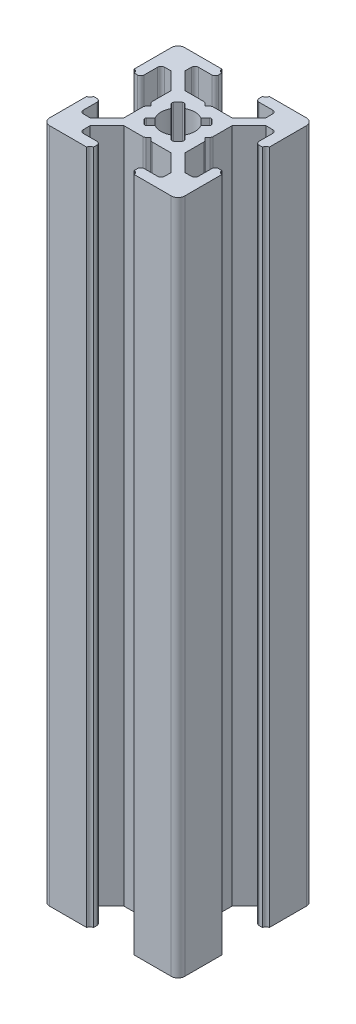
from build123d import *

# Parameters (mm, degrees)
BOSS_EXTRUDE1_DEPTH = 100
FILLET1_R           = 1
CUT_EXTRUDE1_DEPTH  = 101
FILLET2_R           = 0.5
FILLET3_R           = 0.25


with BuildPart() as part:
    # Sketch3 → Boss-Extrude1 (new body)
    with BuildSketch(Plane(origin=(0, 0, 0), x_dir=(1, 0, 0), z_dir=(0, 1, 0))):
        with BuildLine():
            Line((7, 18.5), (7, 19.5))
            ThreePointArc((7, 19.5), (6.646446609, 19.646446609), (6.5, 20))
            Line((6.5, 20), (0, 20))
            Line((0, 20), (0, 13.5))
            ThreePointArc((0, 13.5), (0.353553391, 13.353553391), (0.5, 13))
            Line((0.5, 13), (1.5, 13))
            Line((1.5, 13), (1.5, 16))
            Line((1.5, 16), (3, 16))
            Line((3, 16), (5.5, 13.5))
            Line((5.5, 13.5), (5.5, 10.5))
            Line((5.5, 10.5), (6, 10))
            Line((6, 10), (5.5, 9.5))
            Line((5.5, 9.5), (5.5, 6.5))
            Line((5.5, 6.5), (3, 4))
            Line((3, 4), (1.5, 4))
            Line((1.5, 4), (1.5, 7))
            Line((1.5, 7), (0.5, 7))
            ThreePointArc((0.5, 7), (0.353553391, 6.646446609), (0, 6.5))
            Line((0, 6.5), (0, 0))
            Line((0, 0), (6.5, 0))
            ThreePointArc((6.5, 0), (6.646446609, 0.353553391), (7, 0.5))
            Line((7, 0.5), (7, 1.5))
            Line((7, 1.5), (4, 1.5))
            Line((4, 1.5), (4, 3))
            Line((4, 3), (6.5, 5.5))
            Line((6.5, 5.5), (9.5, 5.5))
            Line((9.5, 5.5), (10, 6))
            Line((10, 6), (10.5, 5.5))
            Line((10.5, 5.5), (13.5, 5.5))
            Line((13.5, 5.5), (16, 3))
            Line((16, 3), (16, 1.5))
            Line((16, 1.5), (13, 1.5))
            Line((13, 1.5), (13, 0.5))
            ThreePointArc((13, 0.5), (13.353553391, 0.353553391), (13.5, 0))
            Line((13.5, 0), (20, 0))
            Line((20, 0), (20, 6.5))
            ThreePointArc((20, 6.5), (19.646446609, 6.646446609), (19.5, 7))
            Line((19.5, 7), (18.5, 7))
            Line((18.5, 7), (18.5, 4))
            Line((18.5, 4), (17, 4))
            Line((17, 4), (14.5, 6.5))
            Line((14.5, 6.5), (14.5, 9.5))
            Line((14.5, 9.5), (14, 10))
            Line((14, 10), (14.5, 10.5))
            Line((14.5, 10.5), (14.5, 13.5))
            Line((14.5, 13.5), (17, 16))
            Line((17, 16), (18.5, 16))
            Line((18.5, 16), (18.5, 13))
            Line((18.5, 13), (19.5, 13))
            ThreePointArc((19.5, 13), (19.646446609, 13.353553391), (20, 13.5))
            Line((20, 13.5), (20, 20))
            Line((20, 20), (13.5, 20))
            ThreePointArc((13.5, 20), (13.353553391, 19.646446609), (13, 19.5))
            Line((13, 19.5), (13, 18.5))
            Line((13, 18.5), (16, 18.5))
            Line((16, 18.5), (16, 17))
            Line((16, 17), (13.5, 14.5))
            Line((13.5, 14.5), (10.5, 14.5))
            Line((10.5, 14.5), (10, 14))
            Line((10, 14), (9.5, 14.5))
            Line((9.5, 14.5), (6.5, 14.5))
            Line((6.5, 14.5), (4, 17))
            Line((4, 17), (4, 18.5))
            Line((4, 18.5), (7, 18.5))
        make_face()
    extrude(amount=BOSS_EXTRUDE1_DEPTH)

    # Fillet1
    fillet1_edges = [part.edges().sort_by_distance(p)[0] for p in [
        (20, 50, 0),
        (0, 50, 0),
        (0, 50, -20),
        (20, 50, -20),
    ]]
    fillet(fillet1_edges, radius=FILLET1_R)

    # Sketch4 → Cut-Extrude1 (cut, through all)
    with BuildSketch(Plane(origin=(0, 100, 0), x_dir=(1, 0, 0), z_dir=(0, 1, 0))):
        with BuildLine():
            Line((10, 11), (11.195582496, 12.195582496))
            ThreePointArc((11.195582496, 12.195582496), (10, 12.5), (8.804417504, 12.195582496))
            Line((8.804417504, 12.195582496), (10, 11))
        make_face()
        with BuildLine():
            ThreePointArc((12.195582496, 11.195582496), (11.767766953, 11.767766953), (11.195582496, 12.195582496))
            Line((11.195582496, 12.195582496), (10, 11))
            Line((10, 11), (11, 10))
            Line((11, 10), (12.195582496, 11.195582496))
        make_face()
        with BuildLine():
            Line((9, 10), (10, 11))
            Line((10, 11), (8.804417504, 12.195582496))
            ThreePointArc((8.804417504, 12.195582496), (8.232233047, 11.767766953), (7.804417504, 11.195582496))
            Line((7.804417504, 11.195582496), (9, 10))
        make_face()
        Polygon((11, 10), (10, 11), (9, 10), (10, 9), align=None)
        with BuildLine():
            Line((7.804417504, 8.804417504), (9, 10))
            Line((9, 10), (7.804417504, 11.195582496))
            ThreePointArc((7.804417504, 11.195582496), (7.5, 10), (7.804417504, 8.804417504))
        make_face()
        with BuildLine():
            Line((10, 9), (9, 10))
            Line((9, 10), (7.804417504, 8.804417504))
            ThreePointArc((7.804417504, 8.804417504), (8.232233047, 8.232233047), (8.804417504, 7.804417504))
            Line((8.804417504, 7.804417504), (10, 9))
        make_face()
        with BuildLine():
            Line((11.195582496, 7.804417504), (10, 9))
            Line((10, 9), (8.804417504, 7.804417504))
            ThreePointArc((8.804417504, 7.804417504), (10, 7.5), (11.195582496, 7.804417504))
        make_face()
        with BuildLine():
            Line((12.195582496, 8.804417504), (11, 10))
            Line((11, 10), (10, 9))
            Line((10, 9), (11.195582496, 7.804417504))
            ThreePointArc((11.195582496, 7.804417504), (11.767766953, 8.232233047), (12.195582496, 8.804417504))
        make_face()
        with BuildLine():
            ThreePointArc((12.5, 10), (12.422700584, 10.616864556), (12.195582496, 11.195582496))
            Line((12.195582496, 11.195582496), (11, 10))
            Line((11, 10), (12.195582496, 8.804417504))
            ThreePointArc((12.195582496, 8.804417504), (12.422700584, 9.383135444), (12.5, 10))
        make_face()
        with BuildLine():
            ThreePointArc((8.804417504, 7.804417504), (8.232233047, 8.232233047), (7.804417504, 8.804417504))
            Line((7.804417504, 8.804417504), (7, 8))
            Line((7, 8), (8, 7))
            Line((8, 7), (8.804417504, 7.804417504))
        make_face()
        with BuildLine():
            Line((13, 8), (12.195582496, 8.804417504))
            ThreePointArc((12.195582496, 8.804417504), (11.767766953, 8.232233047), (11.195582496, 7.804417504))
            Line((11.195582496, 7.804417504), (12, 7))
            Line((12, 7), (13, 8))
        make_face()
        with BuildLine():
            Line((13, 12), (12, 13))
            Line((12, 13), (11.195582496, 12.195582496))
            ThreePointArc((11.195582496, 12.195582496), (11.767766953, 11.767766953), (12.195582496, 11.195582496))
            Line((12.195582496, 11.195582496), (13, 12))
        make_face()
        with BuildLine():
            ThreePointArc((7.804417504, 11.195582496), (8.232233047, 11.767766953), (8.804417504, 12.195582496))
            Line((8.804417504, 12.195582496), (8, 13))
            Line((8, 13), (7, 12))
            Line((7, 12), (7.804417504, 11.195582496))
        make_face()
    extrude(amount=-CUT_EXTRUDE1_DEPTH, mode=Mode.SUBTRACT)

    # Fillet2
    fillet2_edges = [part.edges().sort_by_distance(p)[0] for p in [
        (18.5, 50, -13),
        (18.5, 50, -16),
        (14.5, 50, -10.5),
        (14.5, 50, -9.5),
        (18.5, 50, -4),
        (18.5, 50, -7),
        (13, 50, -1.5),
        (16, 50, -1.5),
        (10.5, 50, -5.5),
        (9.5, 50, -5.5),
        (4, 50, -1.5),
        (7, 50, -1.5),
        (1.5, 50, -7),
        (1.5, 50, -4),
        (5.5, 50, -9.5),
        (5.5, 50, -10.5),
        (1.5, 50, -16),
        (1.5, 50, -13),
        (7, 50, -18.5),
        (4, 50, -18.5),
        (9.5, 50, -14.5),
        (10.5, 50, -14.5),
        (16, 50, -18.5),
        (13, 50, -18.5),
    ]]
    fillet(fillet2_edges, radius=FILLET2_R)

    # Fillet3
    fillet3_edges = [part.edges().sort_by_distance(p)[0] for p in [
        (7, 50, -12),
        (8, 50, -13),
        (12, 50, -13),
        (13, 50, -12),
        (13, 50, -8),
        (12, 50, -7),
        (8, 50, -7),
        (7, 50, -8),
    ]]
    fillet(fillet3_edges, radius=FILLET3_R)


solid = part.part
